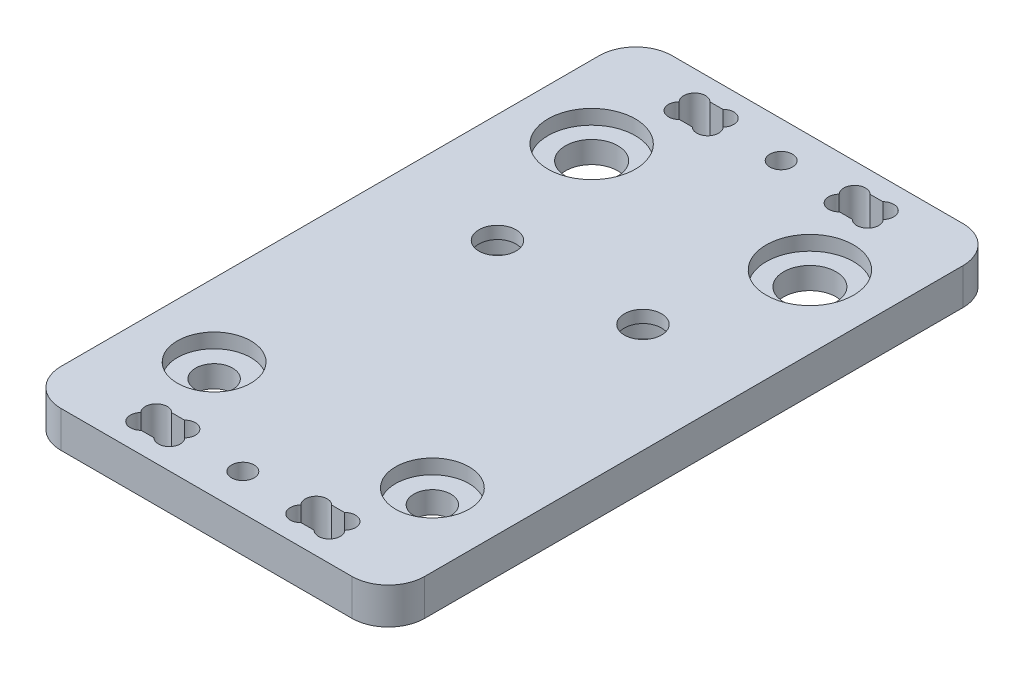
from build123d import *

# Parameters (mm, degrees)
SKETCH1_R               = 3.6
SKETCH1_R_2             = 2.55
BOSS_EXTRUDE1_DEPTH     = 5
SKETCH2_R               = 6
SKETCH2_R_2             = 5.05
CUT_EXTRUDE1_DEPTH      = 2
SALIENTE_EXTRUIR1_DEPTH = 5
CROQUIS5_R              = 2.55
CORTAR_EXTRUIR2_DEPTH   = 6
CROQUIS6_R              = 1.55
CROQUIS6_W              = 6
CROQUIS6_H              = 4.2
CORTAR_EXTRUIR3_DEPTH   = 6
CORTAR_EXTRUIR4_DEPTH   = 6
CROQUIS8_R              = 4.625
CORTAR_EXTRUIR5_DEPTH   = 3.3


with BuildPart() as part:
    # Sketch1 → Boss-Extrude1 (new body)
    with BuildSketch(Plane(origin=(0, 0, 0), x_dir=(1, 0, 0), z_dir=(0, 1, 0))):
        with BuildLine():
            Line((20.365, -35), (-20.365, -35))
            ThreePointArc((-20.365, -35), (-23.642439931, -33.642439931), (-25, -30.365))
            Line((-25, -30.365), (-25, 30.365))
            ThreePointArc((-25, 30.365), (-23.642439931, 33.642439931), (-20.365, 35))
            Line((-20.365, 35), (20.365, 35))
            ThreePointArc((20.365, 35), (23.642439931, 33.642439931), (25, 30.365))
            Line((25, 30.365), (25, -30.365))
            ThreePointArc((25, -30.365), (23.642439931, -33.642439931), (20.365, -35))
        make_face()
        with Locations((-15, 25.95)):
            Circle(SKETCH1_R, mode=Mode.SUBTRACT)
        with Locations((15, 25.95)):
            Circle(SKETCH1_R, mode=Mode.SUBTRACT)
        with Locations((15, -25.95)):
            Circle(SKETCH1_R_2, mode=Mode.SUBTRACT)
        with Locations((-15, -25.95)):
            Circle(SKETCH1_R_2, mode=Mode.SUBTRACT)
    extrude(amount=BOSS_EXTRUDE1_DEPTH)

    # Sketch2 → Cut-Extrude1 (cut)
    with BuildSketch(Plane(origin=(0, 5, 0), x_dir=(1, 0, 0), z_dir=(0, 1, 0))):
        with Locations((-15, 25.95)):
            Circle(SKETCH2_R)
        with Locations((15, 25.95)):
            Circle(SKETCH2_R)
        with Locations((15, -25.95)):
            Circle(SKETCH2_R_2)
        with Locations((-15, -25.95)):
            Circle(SKETCH2_R_2)
    extrude(amount=-CUT_EXTRUDE1_DEPTH, mode=Mode.SUBTRACT)

    # Croquis3 → Saliente-Extruir1 (add)
    with BuildSketch(Plane(origin=(0, 5, 0), x_dir=(1, 0, 0), z_dir=(0, 1, 0))):
        with BuildLine():
            Line((-25, 30.365), (-25, 37))
            ThreePointArc((-25, 37), (-23.535533906, 40.535533906), (-20, 42))
            Line((-20, 42), (20, 42))
            ThreePointArc((20, 42), (23.535533906, 40.535533906), (25, 37))
            Line((25, 37), (25, 30.365))
            ThreePointArc((25, 30.365), (23.642439931, 33.642439931), (20.365, 35))
            Line((20.365, 35), (-20.365, 35))
            ThreePointArc((-20.365, 35), (-23.642439931, 33.642439931), (-25, 30.365))
        make_face()
        with BuildLine():
            Line((-20.365, -35), (20.365, -35))
            ThreePointArc((20.365, -35), (23.642439931, -33.642439931), (25, -30.365))
            Line((25, -30.365), (25, -37))
            ThreePointArc((25, -37), (23.535533906, -40.535533906), (20, -42))
            Line((20, -42), (-20, -42))
            ThreePointArc((-20, -42), (-23.535533906, -40.535533906), (-25, -37))
            Line((-25, -37), (-25, -30.365))
            ThreePointArc((-25, -30.365), (-23.642439931, -33.642439931), (-20.365, -35))
        make_face()
    extrude(amount=-SALIENTE_EXTRUIR1_DEPTH)

    # Croquis5 → Cortar-Extruir2 (cut, through all)
    with BuildSketch(Plane.XZ):
        with Locations((10, -8)):
            Circle(CROQUIS5_R)
        with Locations((-10, -8)):
            Circle(CROQUIS5_R)
    extrude(amount=-CORTAR_EXTRUIR2_DEPTH, mode=Mode.SUBTRACT)

    # Croquis6 → Cortar-Extruir3 (cut, through all)
    with BuildSketch(Plane(origin=(0, 5, 0), x_dir=(1, 0, 0), z_dir=(0, 1, 0))):
        with Locations((0, -37)):
            Circle(CROQUIS6_R)
        with Locations((-11, -37)):
            Rectangle(CROQUIS6_W, CROQUIS6_H)
        with Locations((11, -37)):
            Rectangle(CROQUIS6_W, CROQUIS6_H)
    cortar_extruir3 = extrude(amount=-CORTAR_EXTRUIR3_DEPTH, mode=Mode.SUBTRACT)

    # Croquis7 → Cortar-Extruir4 (cut, through all)
    with BuildSketch(Plane.XZ):
        with BuildLine():
            Line((-11.878679656, 39.1), (-10.121320344, 39.1))
            ThreePointArc((-10.121320344, 39.1), (-8.010608171, 39.110503119), (-7.979099854, 37))
            ThreePointArc((-7.979099854, 37), (-8.010608171, 34.889496881), (-10.121320344, 34.9))
            Line((-10.121320344, 34.9), (-11.878679656, 34.9))
            ThreePointArc((-11.878679656, 34.9), (-13.989391829, 34.889496881), (-14.020900146, 37))
            ThreePointArc((-14.020900146, 37), (-13.989391829, 39.110503119), (-11.878679656, 39.1))
        make_face()
        with BuildLine():
            Line((11.878679656, 34.9), (10.121320344, 34.9))
            ThreePointArc((10.121320344, 34.9), (8.010608171, 34.889496881), (7.979099854, 37))
            ThreePointArc((7.979099854, 37), (8.010608171, 39.110503119), (10.121320344, 39.1))
            Line((10.121320344, 39.1), (11.878679656, 39.1))
            ThreePointArc((11.878679656, 39.1), (13.989391829, 39.110503119), (14.020900146, 37))
            ThreePointArc((14.020900146, 37), (13.989391829, 34.889496881), (11.878679656, 34.9))
        make_face()
    cortar_extruir4 = extrude(amount=-CORTAR_EXTRUIR4_DEPTH, mode=Mode.SUBTRACT)

    # Croquis8 → Cortar-Extruir5 (cut)
    with BuildSketch(Plane.XZ):
        with Locations((-10, -8)):
            Circle(CROQUIS8_R)
        with Locations((10, -8)):
            Circle(CROQUIS8_R)
    extrude(amount=-CORTAR_EXTRUIR5_DEPTH, mode=Mode.SUBTRACT)

    # Simetría1: Cortar-Extruir3, Cortar-Extruir4 across plane
    add(cortar_extruir3.mirror(Plane.XY), mode=Mode.SUBTRACT)
    add(cortar_extruir4.mirror(Plane.XY), mode=Mode.SUBTRACT)


solid = part.part
